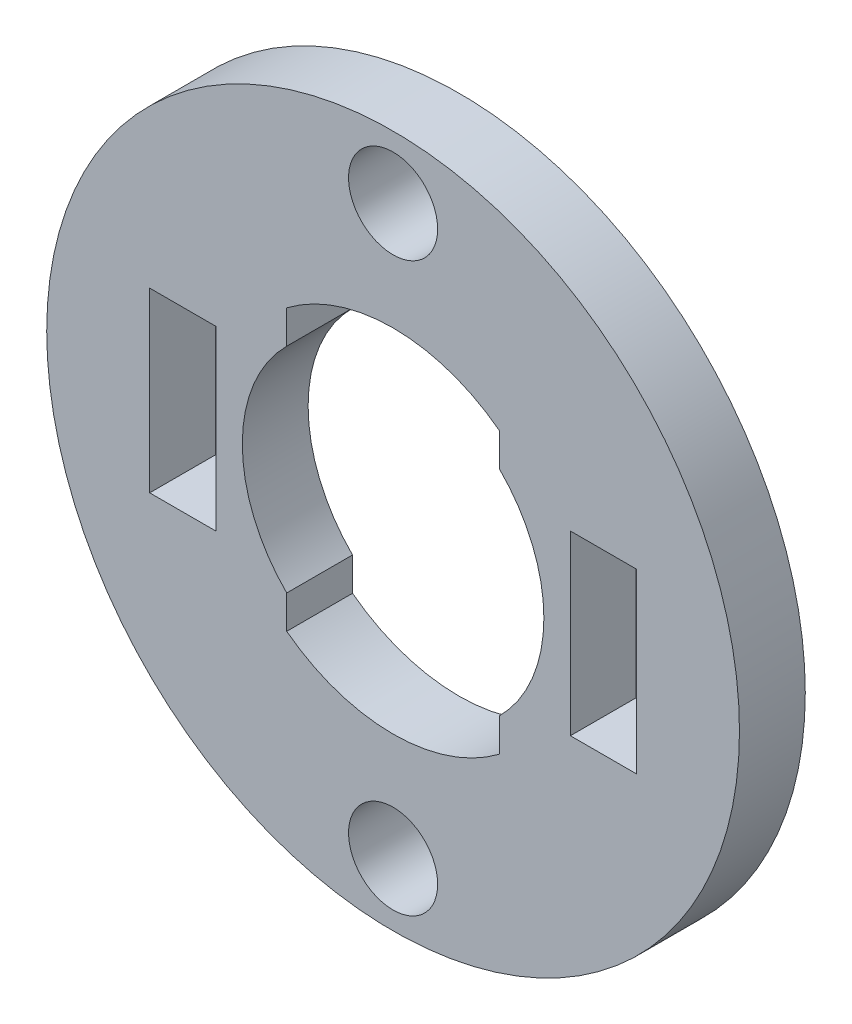
from build123d import *

# Parameters (mm, degrees)
SKETCH1_R                   = 15.5067
BOSS_EXTRUDE1_DEPTH         = 2.9464
CUT_EXTRUDE1_REACH          = 24.127
CUT_EXTRUDE2_REACH          = 24.127
SKETCH3_W                   = 2.9591
SKETCH3_H                   = 7.9375
TAP_DRILL_FOR_4_HELICOIL1_D = 3.9878


with BuildPart() as part:
    # Sketch1 → Boss-Extrude1 (new body)
    with BuildSketch(Plane.XY):
        Circle(SKETCH1_R)
    extrude(amount=BOSS_EXTRUDE1_DEPTH)

    # Sketch2 → Cut-Extrude1 (cut, up to next)
    with BuildSketch(Plane.XY.offset(2.9464), mode=Mode.PRIVATE) as cut_extrude1_sk1:
        with BuildLine():
            Line((4.7625, 6.270444143), (4.7625, 4.783418626))
            ThreePointArc((4.7625, 4.783418626), (6.75, 0), (4.7625, -4.783418626))
            Line((4.7625, -4.783418626), (4.7625, -6.270444143))
            ThreePointArc((4.7625, -6.270444143), (0, -7.874), (-4.7625, -6.270444143))
            Line((-4.7625, -6.270444143), (-4.7625, -4.783418626))
            ThreePointArc((-4.7625, -4.783418626), (-6.75, 0), (-4.7625, 4.783418626))
            Line((-4.7625, 4.783418626), (-4.7625, 6.270444143))
            ThreePointArc((-4.7625, 6.270444143), (0, 7.874), (4.7625, 6.270444143))
        make_face()
    cut_extrude1_tool1 = extrude(cut_extrude1_sk1.sketch, amount=-CUT_EXTRUDE1_REACH, mode=Mode.PRIVATE) & part.part
    add(cut_extrude1_tool1.solids().sort_by_distance((0, 0, 2.9464))[0], mode=Mode.SUBTRACT)

    # Sketch3 → Cut-Extrude2 (cut, up to next)
    with BuildSketch(Plane(origin=(0, 0, 0), x_dir=(-1, 0, 0), z_dir=(0, 0, -1)), mode=Mode.PRIVATE) as cut_extrude2_sk1:
        with Locations((-9.41705, 0)):
            Rectangle(SKETCH3_W, SKETCH3_H)
    cut_extrude2_tool1 = extrude(cut_extrude2_sk1.sketch, amount=-CUT_EXTRUDE2_REACH, mode=Mode.PRIVATE) & part.part
    cut_extrude2 = cut_extrude2_tool1.solids().sort_by_distance((9.41705, 0, 0))[0]
    add(cut_extrude2, mode=Mode.SUBTRACT)

    # Mirror1: Cut-Extrude2 across plane
    add(cut_extrude2.mirror(Plane(origin=(0, 0, 0), x_dir=(0, 0, 1), z_dir=(1, 0, 0))), mode=Mode.SUBTRACT)

    # Tap Drill for #4 Helicoil1 (through all)
    with Locations(Plane.XY.offset(2.9464)):
        with Locations((0, 12.7), (0, -12.7)):
            Hole(TAP_DRILL_FOR_4_HELICOIL1_D / 2)


solid = part.part
